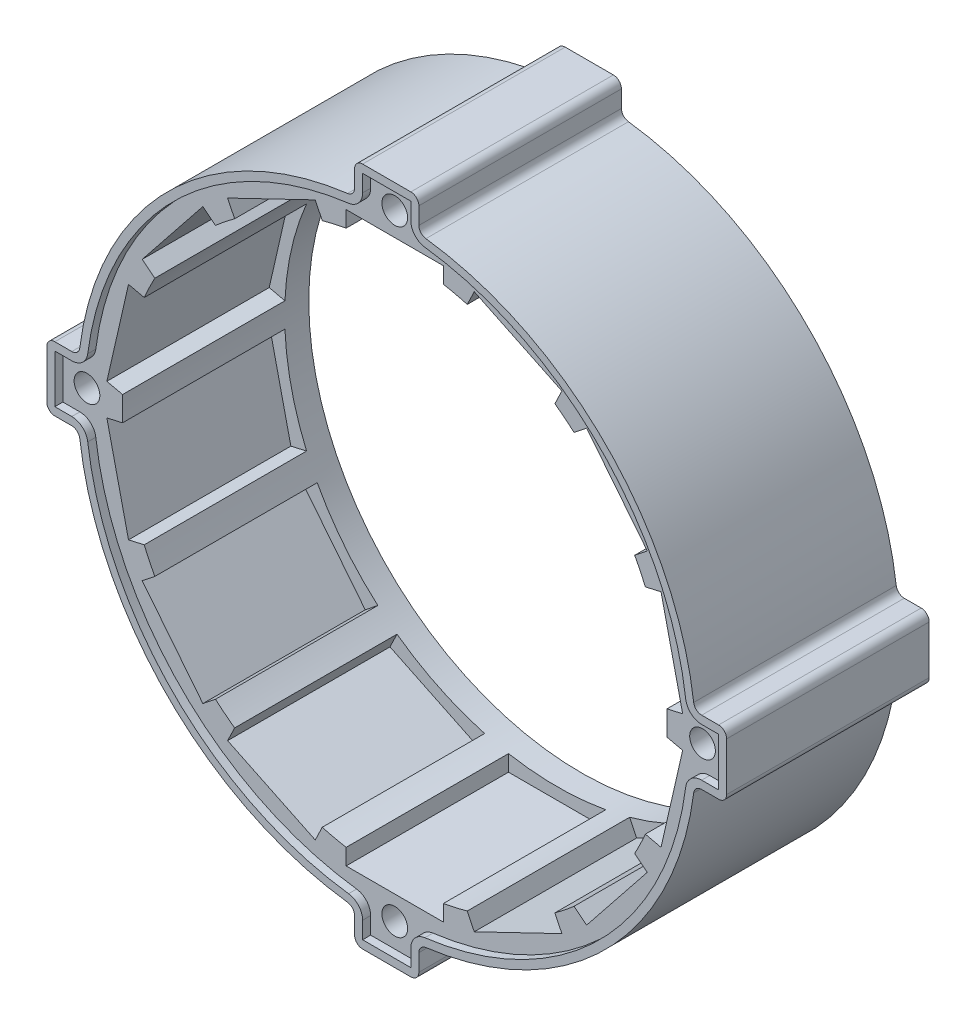
from build123d import *

# Parameters (mm, degrees)
SKETCH_1_R               = 38.5
EXTRUDE_1_DEPTH          = 20.2
SKETCH_3_W               = 12.1
SKETCH_3_H               = 2.5
CUT_EXTRUDE_2_DEPTH      = 59.073574025
PATTERN_CIRCULAR_2_COUNT = 14
SKETCH_5_R               = 38.5
SKETCH_5_R_2             = 33.9
EXTRUDE_2_DEPTH          = 3
SKETCH_6_R               = 33.9
CUT_EXTRUDE_3_DEPTH      = 60.183950527
EXTRUDE_3_DEPTH          = 23.2
PATTERN_CIRCULAR_3_COUNT = 4
SKETCH_8_R               = 1.6
CUT_EXTRUDE_4_DEPTH      = 65.151432595
FILLET_1_R               = 1
EXTRUDE_4_DEPTH          = 1
EXTRUDE_6_DEPTH          = 1


with BuildPart() as part:
    # ｽｹｯﾁ1 → ﾎﾞｽ - 押し出し1 (new body)
    with BuildSketch(Plane.XY):
        Circle(SKETCH_1_R)
        Polygon((33.704694056, 0), (30.366880046, 14.623918683), (21.014533019, 26.35139092), (7.5, 32.859647007), (-7.5, 32.859647007), (-21.014533019, 26.35139092), (-30.366880046, 14.623918683), (-33.704694056, 0), (-30.366880046, -14.623918683), (-21.014533019, -26.35139092), (-7.5, -32.859647007), (7.5, -32.859647007), (21.014533019, -26.35139092), (30.366880046, -14.623918683), align=None, mode=Mode.SUBTRACT)
    extrude(amount=EXTRUDE_1_DEPTH)

    # ｽｹｯﾁ3 → ｶｯﾄ - 押し出し2 (cut, through all)
    with BuildSketch(Plane.XY.offset(20.2)):
        with Locations((0, 34.109647007)):
            Rectangle(SKETCH_3_W, SKETCH_3_H)
    cut_extrude_2 = extrude(amount=-CUT_EXTRUDE_2_DEPTH, mode=Mode.SUBTRACT)

    # 円形ﾊﾟﾀｰﾝ2: ｶｯﾄ - 押し出し2 ×14 about axis
    pattern_circular_2_axis = Axis((0, 0, 0), (0, 0, 1))
    for i in range(1, PATTERN_CIRCULAR_2_COUNT):
        add(cut_extrude_2.rotate(pattern_circular_2_axis, i * 360 / PATTERN_CIRCULAR_2_COUNT), mode=Mode.SUBTRACT)

    # ｽｹｯﾁ5 → ﾎﾞｽ - 押し出し2 (add)
    with BuildSketch(Plane(origin=(0, 0, 0), x_dir=(-1, 0, 0), z_dir=(0, 0, -1))):
        Circle(SKETCH_5_R)
        with Locations(Location((0, 0, 0), (0, 0, 182.576717009))):
            Circle(SKETCH_5_R_2, mode=Mode.SUBTRACT)
    extrude(amount=EXTRUDE_2_DEPTH)

    # ｽｹｯﾁ6 → ｶｯﾄ - 押し出し3 (cut, through all)
    with BuildSketch(Plane(origin=(0, 0, -3), x_dir=(-1, 0, 0), z_dir=(0, 0, -1))):
        with Locations(Location((0, 0, 0), (0, 0, 182.576717009))):
            Circle(SKETCH_6_R)
    extrude(amount=-CUT_EXTRUDE_3_DEPTH, mode=Mode.SUBTRACT)

    # ｽｹｯﾁ7 → ﾎﾞｽ - 押し出し3 (add)
    with BuildSketch(Plane(origin=(0, 0, -3), x_dir=(-1, 0, 0), z_dir=(0, 0, -1))):
        with BuildLine():
            Line((4, 42.291643997), (-4, 42.291643997))
            Line((-4, 42.291643997), (-4, 38.291643997))
            ThreePointArc((-4, 38.291643997), (0, 38.5), (4, 38.291643997))
            Line((4, 38.291643997), (4, 42.291643997))
        make_face()
    extrude_3 = extrude(amount=-EXTRUDE_3_DEPTH)

    # 円形ﾊﾟﾀｰﾝ3: ﾎﾞｽ - 押し出し3 ×4 about axis
    pattern_circular_3_axis = Axis((0, 0, 0), (0, 0, 1))
    for i in range(1, PATTERN_CIRCULAR_3_COUNT):
        add(extrude_3.rotate(pattern_circular_3_axis, i * 360 / PATTERN_CIRCULAR_3_COUNT))

    # ｽｹｯﾁ8 → ｶｯﾄ - 押し出し4 (cut, through all)
    with BuildSketch(Plane(origin=(0, 0, -3), x_dir=(-1, 0, 0), z_dir=(0, 0, -1))):
        with Locations((0, 38.291643997)):
            Circle(SKETCH_8_R)
        with Locations((38.291643997, 0)):
            Circle(SKETCH_8_R)
        with Locations((0, -38.291643997)):
            Circle(SKETCH_8_R)
        with Locations((-38.291643997, 0)):
            Circle(SKETCH_8_R)
    extrude(amount=-CUT_EXTRUDE_4_DEPTH, mode=Mode.SUBTRACT)

    # ﾌｨﾚｯﾄ1
    fillet_1_edges = [part.edges().sort_by_distance(p)[0] for p in [
        (-4, 42.291643997, 8.6),
        (4, 42.291643997, 8.6),
        (4, 38.291643997, 8.6),
        (-4, 38.291643997, 8.6),
        (-42.291643997, -4, 8.6),
        (-42.291643997, 4, 8.6),
        (-38.291643997, 4, 8.6),
        (-38.291643997, -4, 8.6),
        (4, -42.291643997, 8.6),
        (-4, -42.291643997, 8.6),
        (-4, -38.291643997, 8.6),
        (4, -38.291643997, 8.6),
        (42.291643997, 4, 8.6),
        (42.291643997, -4, 8.6),
        (38.291643997, -4, 8.6),
        (38.291643997, 4, 8.6),
    ]]
    fillet(fillet_1_edges, radius=FILLET_1_R)

    # ｽｹｯﾁ9 → ﾎﾞｽ - 押し出し4 (add)
    with BuildSketch(Plane(origin=(0, 0, -3), x_dir=(-1, 0, 0), z_dir=(0, 0, -1))):
        with BuildLine():
            Line((-4, -39.182266397), (-4, -41.291643997))
            ThreePointArc((-4, -41.291643997), (-3.707106781, -41.998750778), (-3, -42.291643997))
            Line((-3, -42.291643997), (3, -42.291643997))
            ThreePointArc((3, -42.291643997), (3.707106781, -41.998750778), (4, -41.291643997))
            Line((4, -41.291643997), (4, -39.182266397))
            ThreePointArc((4, -39.182266397), (4.249472759, -38.521426885), (4.873417722, -38.190310286))
            ThreePointArc((4.873417722, -38.190310286), (27.223611076, -27.223611076), (38.190310286, -4.873417722))
            ThreePointArc((38.190310286, -4.873417722), (38.521426885, -4.249472759), (39.182266397, -4))
            Line((39.182266397, -4), (41.291643997, -4))
            ThreePointArc((41.291643997, -4), (41.998750778, -3.707106781), (42.291643997, -3))
            Line((42.291643997, -3), (42.291643997, 3))
            ThreePointArc((42.291643997, 3), (41.998750778, 3.707106781), (41.291643997, 4))
            Line((41.291643997, 4), (39.182266397, 4))
            ThreePointArc((39.182266397, 4), (38.521426885, 4.249472759), (38.190310286, 4.873417722))
            ThreePointArc((38.190310286, 4.873417722), (27.223611076, 27.223611076), (4.873417722, 38.190310286))
            ThreePointArc((4.873417722, 38.190310286), (4.249472759, 38.521426885), (4, 39.182266397))
            Line((4, 39.182266397), (4, 41.291643997))
            ThreePointArc((4, 41.291643997), (3.707106781, 41.998750778), (3, 42.291643997))
            Line((3, 42.291643997), (-3, 42.291643997))
            ThreePointArc((-3, 42.291643997), (-3.707106781, 41.998750778), (-4, 41.291643997))
            Line((-4, 41.291643997), (-4, 39.182266397))
            ThreePointArc((-4, 39.182266397), (-4.249472759, 38.521426885), (-4.873417722, 38.190310286))
            ThreePointArc((-4.873417722, 38.190310286), (-27.223611076, 27.223611076), (-38.190310286, 4.873417722))
            ThreePointArc((-38.190310286, 4.873417722), (-38.521426885, 4.249472759), (-39.182266397, 4))
            Line((-39.182266397, 4), (-41.291643997, 4))
            ThreePointArc((-41.291643997, 4), (-41.998750778, 3.707106781), (-42.291643997, 3))
            Line((-42.291643997, 3), (-42.291643997, -3))
            ThreePointArc((-42.291643997, -3), (-41.998750778, -3.707106781), (-41.291643997, -4))
            Line((-41.291643997, -4), (-39.182266397, -4))
            ThreePointArc((-39.182266397, -4), (-38.521426885, -4.249472759), (-38.190310286, -4.873417722))
            ThreePointArc((-38.190310286, -4.873417722), (-27.223611076, -27.223611076), (-4.873417722, -38.190310286))
            ThreePointArc((-4.873417722, -38.190310286), (-4.249472759, -38.521426885), (-4, -39.182266397))
        make_face()
        with BuildLine():
            Line((-3, -39.182266397), (-3, -41.291643997))
            Line((-3, -41.291643997), (3, -41.291643997))
            Line((3, -41.291643997), (3, -39.182266397))
            ThreePointArc((3, -39.182266397), (3.498945518, -37.860587373), (4.746835443, -37.198354174))
            ThreePointArc((4.746835443, -37.198354174), (26.516504294, -26.516504294), (37.198354174, -4.746835443))
            ThreePointArc((37.198354174, -4.746835443), (37.860587373, -3.498945518), (39.182266397, -3))
            Line((39.182266397, -3), (41.291643997, -3))
            Line((41.291643997, -3), (41.291643997, 3))
            Line((41.291643997, 3), (39.182266397, 3))
            ThreePointArc((39.182266397, 3), (37.860587373, 3.498945518), (37.198354174, 4.746835443))
            ThreePointArc((37.198354174, 4.746835443), (26.516504294, 26.516504294), (4.746835443, 37.198354174))
            ThreePointArc((4.746835443, 37.198354174), (3.498945518, 37.860587373), (3, 39.182266397))
            Line((3, 39.182266397), (3, 41.291643997))
            Line((3, 41.291643997), (-3, 41.291643997))
            Line((-3, 41.291643997), (-3, 39.182266397))
            ThreePointArc((-3, 39.182266397), (-3.498945518, 37.860587373), (-4.746835443, 37.198354174))
            ThreePointArc((-4.746835443, 37.198354174), (-26.516504294, 26.516504294), (-37.198354174, 4.746835443))
            ThreePointArc((-37.198354174, 4.746835443), (-37.860587373, 3.498945518), (-39.182266397, 3))
            Line((-39.182266397, 3), (-41.291643997, 3))
            Line((-41.291643997, 3), (-41.291643997, -3))
            Line((-41.291643997, -3), (-39.182266397, -3))
            ThreePointArc((-39.182266397, -3), (-37.860587373, -3.498945518), (-37.198354174, -4.746835443))
            ThreePointArc((-37.198354174, -4.746835443), (-26.516504294, -26.516504294), (-4.746835443, -37.198354174))
            ThreePointArc((-4.746835443, -37.198354174), (-3.498945518, -37.860587373), (-3, -39.182266397))
        make_face(mode=Mode.SUBTRACT)
    extrude(amount=EXTRUDE_4_DEPTH)

    # ｽｹｯﾁ10 → ﾎﾞｽ - 押し出し6 (add)
    with BuildSketch(Plane.XY.offset(20.2)):
        with BuildLine():
            Line((-3, -42.291643997), (3, -42.291643997))
            ThreePointArc((3, -42.291643997), (3.707106781, -41.998750778), (4, -41.291643997))
            Line((4, -41.291643997), (4, -39.182266397))
            ThreePointArc((4, -39.182266397), (4.249472759, -38.521426885), (4.873417722, -38.190310286))
            ThreePointArc((4.873417722, -38.190310286), (27.223611076, -27.223611076), (38.190310286, -4.873417722))
            ThreePointArc((38.190310286, -4.873417722), (38.521426885, -4.249472759), (39.182266397, -4))
            Line((39.182266397, -4), (41.291643997, -4))
            ThreePointArc((41.291643997, -4), (41.998750778, -3.707106781), (42.291643997, -3))
            Line((42.291643997, -3), (42.291643997, 3))
            ThreePointArc((42.291643997, 3), (41.998750778, 3.707106781), (41.291643997, 4))
            Line((41.291643997, 4), (39.182266397, 4))
            ThreePointArc((39.182266397, 4), (38.521426885, 4.249472759), (38.190310286, 4.873417722))
            ThreePointArc((38.190310286, 4.873417722), (27.223611076, 27.223611076), (4.873417722, 38.190310286))
            ThreePointArc((4.873417722, 38.190310286), (4.249472759, 38.521426885), (4, 39.182266397))
            Line((4, 39.182266397), (4, 41.291643997))
            ThreePointArc((4, 41.291643997), (3.707106781, 41.998750778), (3, 42.291643997))
            Line((3, 42.291643997), (-3, 42.291643997))
            ThreePointArc((-3, 42.291643997), (-3.707106781, 41.998750778), (-4, 41.291643997))
            Line((-4, 41.291643997), (-4, 39.182266397))
            ThreePointArc((-4, 39.182266397), (-4.249472759, 38.521426885), (-4.873417722, 38.190310286))
            ThreePointArc((-4.873417722, 38.190310286), (-27.223611076, 27.223611076), (-38.190310286, 4.873417722))
            ThreePointArc((-38.190310286, 4.873417722), (-38.521426885, 4.249472759), (-39.182266397, 4))
            Line((-39.182266397, 4), (-41.291643997, 4))
            ThreePointArc((-41.291643997, 4), (-41.998750778, 3.707106781), (-42.291643997, 3))
            Line((-42.291643997, 3), (-42.291643997, -3))
            ThreePointArc((-42.291643997, -3), (-41.998750778, -3.707106781), (-41.291643997, -4))
            Line((-41.291643997, -4), (-39.182266397, -4))
            ThreePointArc((-39.182266397, -4), (-38.521426885, -4.249472759), (-38.190310286, -4.873417722))
            ThreePointArc((-38.190310286, -4.873417722), (-27.223611076, -27.223611076), (-4.873417722, -38.190310286))
            ThreePointArc((-4.873417722, -38.190310286), (-4.249472759, -38.521426885), (-4, -39.182266397))
            Line((-4, -39.182266397), (-4, -41.291643997))
            ThreePointArc((-4, -41.291643997), (-3.707106781, -41.998750778), (-3, -42.291643997))
        make_face()
        with BuildLine():
            Line((-3, -41.291643997), (3, -41.291643997))
            Line((3, -41.291643997), (3, -39.182266397))
            ThreePointArc((3, -39.182266397), (3.498945518, -37.860587373), (4.746835443, -37.198354174))
            ThreePointArc((4.746835443, -37.198354174), (26.516504294, -26.516504294), (37.198354174, -4.746835443))
            ThreePointArc((37.198354174, -4.746835443), (37.860587373, -3.498945518), (39.182266397, -3))
            Line((39.182266397, -3), (41.291643997, -3))
            Line((41.291643997, -3), (41.291643997, 3))
            Line((41.291643997, 3), (39.182266397, 3))
            ThreePointArc((39.182266397, 3), (37.860587373, 3.498945518), (37.198354174, 4.746835443))
            ThreePointArc((37.198354174, 4.746835443), (26.516504294, 26.516504294), (4.746835443, 37.198354174))
            ThreePointArc((4.746835443, 37.198354174), (3.498945518, 37.860587373), (3, 39.182266397))
            Line((3, 39.182266397), (3, 41.291643997))
            Line((3, 41.291643997), (-3, 41.291643997))
            Line((-3, 41.291643997), (-3, 39.182266397))
            ThreePointArc((-3, 39.182266397), (-3.498945518, 37.860587373), (-4.746835443, 37.198354174))
            ThreePointArc((-4.746835443, 37.198354174), (-26.516504294, 26.516504294), (-37.198354174, 4.746835443))
            ThreePointArc((-37.198354174, 4.746835443), (-37.860587373, 3.498945518), (-39.182266397, 3))
            Line((-39.182266397, 3), (-41.291643997, 3))
            Line((-41.291643997, 3), (-41.291643997, -3))
            Line((-41.291643997, -3), (-39.182266397, -3))
            ThreePointArc((-39.182266397, -3), (-37.860587373, -3.498945518), (-37.198354174, -4.746835443))
            ThreePointArc((-37.198354174, -4.746835443), (-26.516504294, -26.516504294), (-4.746835443, -37.198354174))
            ThreePointArc((-4.746835443, -37.198354174), (-3.498945518, -37.860587373), (-3, -39.182266397))
            Line((-3, -39.182266397), (-3, -41.291643997))
        make_face(mode=Mode.SUBTRACT)
    extrude(amount=EXTRUDE_6_DEPTH)


solid = part.part
